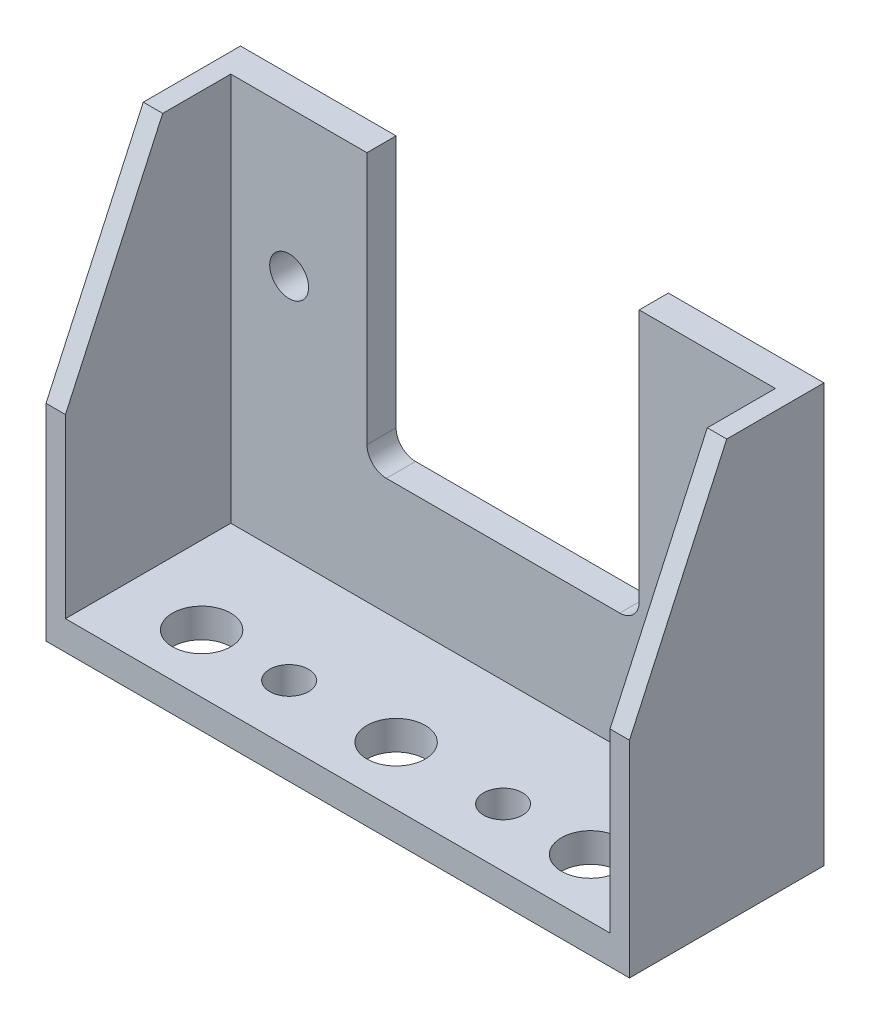
from build123d import *

# Parameters (mm, degrees)
SKETCH1_W           = 30
SKETCH1_H           = 10
SKETCH1_R           = 1.5
BOSS_EXTRUDE1_DEPTH = 0.75
SKETCH2_R           = 1.5
SKETCH2_R_2         = 1
CUT_EXTRUDE1_DEPTH  = 1.5
BOSS_EXTRUDE3_START = -4.25
BOSS_EXTRUDE3_DEPTH = 0.75
SKETCH4_R           = 1
CUT_EXTRUDE2_DEPTH  = 10
FILLET1_R           = 1
BOSS_EXTRUDE4_START = 14
BOSS_EXTRUDE4_DEPTH = 1


with BuildPart() as part:
    # Sketch1 → Boss-Extrude1 (new body, symmetric)
    with BuildSketch(Plane(origin=(0, 0, 0), x_dir=(1, 0, 0), z_dir=(0, 1, 0))):
        Rectangle(SKETCH1_W, SKETCH1_H)
        with Locations((0, -2)):
            Circle(SKETCH1_R, mode=Mode.SUBTRACT)
    extrude(amount=BOSS_EXTRUDE1_DEPTH, both=True)

    # Sketch2 → Cut-Extrude1 (cut)
    with BuildSketch(Plane(origin=(0, 0.75, 0), x_dir=(1, 0, 0), z_dir=(0, 1, 0))):
        with Locations((-10, -2)):
            Circle(SKETCH2_R)
        with Locations((10, -2)):
            Circle(SKETCH2_R)
        with Locations((-5.5, -2)):
            Circle(SKETCH2_R_2)
        with Locations((5.5, -2)):
            Circle(SKETCH2_R_2)
    extrude(amount=-CUT_EXTRUDE1_DEPTH, mode=Mode.SUBTRACT)

    # Sketch3 → Boss-Extrude3 (add, symmetric)
    with BuildSketch(Plane.XY.offset(BOSS_EXTRUDE3_START)):
        Polygon((15, 0.75), (15, 20.75), (7, 20.75), (7, 6.75), (-7, 6.75), (-7, 20.75), (-15, 20.75), (-15, 0.75), align=None)
    extrude(amount=BOSS_EXTRUDE3_DEPTH, both=True)

    # Sketch4 → Cut-Extrude2 (cut)
    with BuildSketch(Plane.XY):
        with Locations((-11, 13.25)):
            Circle(SKETCH4_R)
        with Locations((11, 13.25)):
            Circle(SKETCH4_R)
    extrude(amount=-CUT_EXTRUDE2_DEPTH, mode=Mode.SUBTRACT)

    # Fillet1
    fillet1_edges = [part.edges().sort_by_distance(p)[0] for p in [
        (7, 6.75, -4.25),
        (-7, 6.75, -4.25),
    ]]
    fillet(fillet1_edges, radius=FILLET1_R)

    # Sketch7 → Boss-Extrude4 (add)
    with BuildSketch(Plane(origin=(0, 0, 0), x_dir=(0, 0, -1), z_dir=(1, 0, 0)).offset(BOSS_EXTRUDE4_START)):
        Polygon((3.5, 0.75), (3.5, 20.75), (0, 20.75), (-5, 9.840050856), (-5, 0.75), align=None)
    boss_extrude4 = extrude(amount=BOSS_EXTRUDE4_DEPTH)

    # Mirror1: Boss-Extrude4 across plane
    add(boss_extrude4.mirror(Plane(origin=(0, 0, 0), x_dir=(0, 0, 1), z_dir=(1, 0, 0))))


solid = part.part
